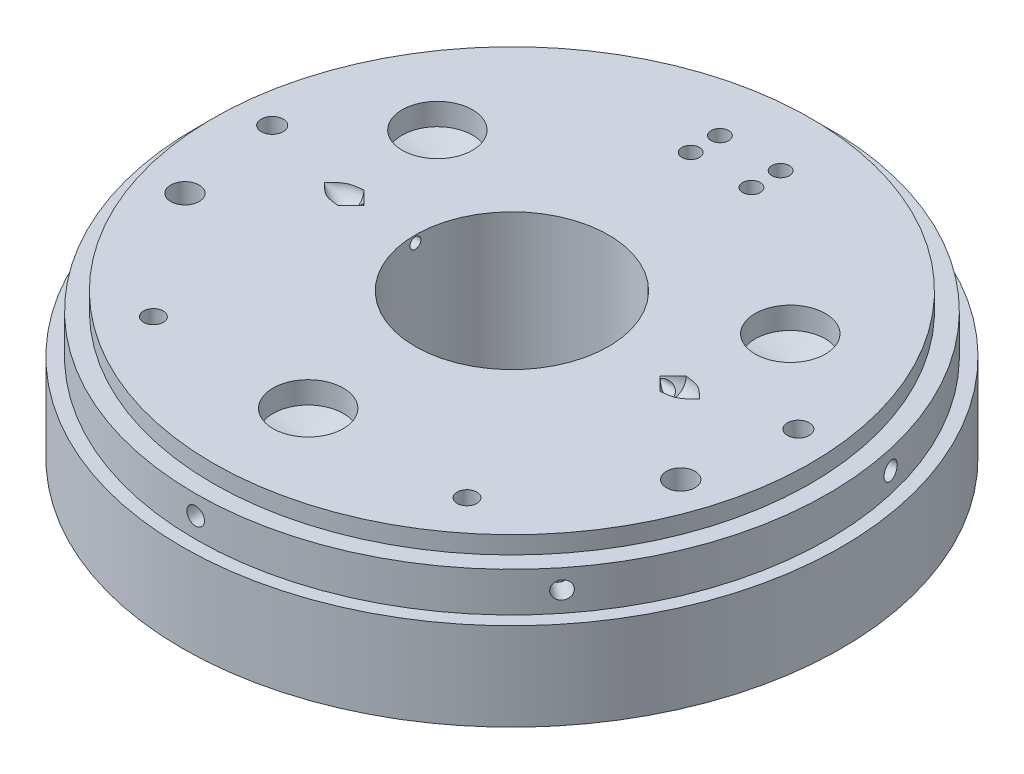
from build123d import *

# Parameters (mm, degrees)
SKETCH1_R                   = 150
EXTRUDE1_DEPTH              = 40
SKETCH2_R                   = 144
EXTRUDE2_DEPTH              = 18
SKETCH3_R                   = 136
EXTRUDE4_DEPTH              = 8
SKETCH7_R                   = 44
EXTRUDE11_DEPTH             = 100
SKETCH11_R                  = 16
EXTRUDE12_DEPTH             = 10
CIRPATTERN4_COUNT           = 3
SKETCH16_R                  = 2.5
EXTRUDE13_DEPTH             = 30
CIRPATTERN6_COUNT           = 2
SKETCH18_R                  = 5
EXTRUDE19_DEPTH             = 18
SKETCH22_R                  = 6.5
EXTRUDE20_DEPTH             = 18
SKETCH23_R                  = 4.5
EXTRUDE21_DEPTH             = 18
SKETCH24_R                  = 4
EXTRUDE23_DEPTH             = 8
SKETCH25_R                  = 16
EXTRUDE25_DEPTH             = 4
EXTRUDE25_DRAFT             = -75
CIRPATTERN7_COPY_1_SKETCH_R = 16
CIRPATTERN7_COPY_1_DEPTH    = 4
CIRPATTERN7_COPY_1_DRAFT    = -75
CIRPATTERN7_COPY_2_SKETCH_R = 16
CIRPATTERN7_COPY_2_DEPTH    = 4
CIRPATTERN7_COPY_2_DRAFT    = -75
SKETCH5_R                   = 4
EXTRUDE33_DEPTH             = 10
SKETCH33_R                  = 2
EXTRUDE34_DEPTH             = 5
CIRPATTERN10_COUNT          = 7


with BuildPart() as part:
    # Sketch1 → Extrude1 (new body)
    with BuildSketch(Plane(origin=(0, 0, 0), x_dir=(1, 0, 0), z_dir=(0, 1, 0))):
        with Locations(Location((0, 0, 0), (0, 0, 270))):
            Circle(SKETCH1_R)
    extrude(amount=EXTRUDE1_DEPTH)

    # Sketch2 → Extrude2 (add)
    with BuildSketch(Plane(origin=(0, 40, 0), x_dir=(1, 0, 0), z_dir=(0, 1, 0))):
        with Locations(Location((0, 0, 0), (0, 0, 270))):
            Circle(SKETCH2_R)
    extrude(amount=EXTRUDE2_DEPTH)

    # Sketch3 → Extrude4 (add)
    with BuildSketch(Plane(origin=(0, 58, 0), x_dir=(1, 0, 0), z_dir=(0, 1, 0))):
        with Locations(Location((0, 0, 0), (0, 0, 270))):
            Circle(SKETCH3_R)
    extrude(amount=EXTRUDE4_DEPTH)

    # Sketch7 → Extrude11 (cut)
    with BuildSketch(Plane(origin=(0, 66, 0), x_dir=(-1, 0, 0), z_dir=(0, 1, 0))):
        with Locations(Location((0, 0, 0), (0, 0, 90))):
            Circle(SKETCH7_R)
    extrude(amount=-EXTRUDE11_DEPTH, mode=Mode.SUBTRACT)

    # Sketch11 → Extrude12 (cut)
    with BuildSketch(Plane(origin=(0, 66, 0), x_dir=(1, 0, 0), z_dir=(0, 1, 0))):
        with Locations(Location((0, -92.741441023, 0), (0, 0, 270))):
            Circle(SKETCH11_R)
    extrude12 = extrude(amount=-EXTRUDE12_DEPTH, mode=Mode.SUBTRACT)

    # CirPattern4: Extrude12 ×3 about axis
    cirpattern4_axis = Axis((0, 0, 0), (0, 1, 0))
    for i in range(1, CIRPATTERN4_COUNT):
        add(extrude12.rotate(cirpattern4_axis, i * 360 / CIRPATTERN4_COUNT), mode=Mode.SUBTRACT)

    # Sketch14 → Cut-Revolve1 (revolve, cut)
    with BuildSketch(Plane(origin=(0, 66, 0), x_dir=(1, 0, 0), z_dir=(0, 1, 0))):
        with BuildLine():
            Line((-73.357030194, 0), (-67.278961327, 0))
            Line((-67.278961327, 0), (-73.357030194, 6))
            add(Edge.make_bspline(
                [(-85.357030194, 0), (-83.501718756, 1.9200594), (-80.173424478, 5.36450683), (-75.448230423, 5.805037179), (-73.357030194, 6)],
                knots=[0, 0, 0, 0, 0.557436117, 1, 1, 1, 1], degree=3))
            Line((-85.357030194, 0), (-73.357030194, 0))
        make_face()
    cut_revolve1 = revolve(axis=Axis((0, 66, 0), (-1, 0, 0)), mode=Mode.SUBTRACT)

    # Sketch16 → Extrude13 (cut)
    with BuildSketch(Plane(origin=(-43, 0, 0), x_dir=(0, 0, -1), z_dir=(1, 0, 0))):
        with Locations((0, 62.819634253)):
            Circle(SKETCH16_R)
    extrude13 = extrude(amount=-EXTRUDE13_DEPTH, mode=Mode.SUBTRACT)

    # CirPattern6: Cut-Revolve1, Extrude13 ×2 about axis
    cirpattern6_axis = Axis((0, 40, 0), (0, -1, 0))
    add([cut_revolve1.rotate(cirpattern6_axis, i * 360 / CIRPATTERN6_COUNT) for i in range(1, CIRPATTERN6_COUNT)], mode=Mode.SUBTRACT)
    add([extrude13.rotate(cirpattern6_axis, i * 360 / CIRPATTERN6_COUNT) for i in range(1, CIRPATTERN6_COUNT)], mode=Mode.SUBTRACT)

    # Sketch18 → Extrude19 (cut)
    with BuildSketch(Plane(origin=(0, 66, 0), x_dir=(-1, 0, 0), z_dir=(0, 1, 0))):
        with Locations(Location((-119.722485041, -10.622792815, 0), (0, 0, 90))):
            Circle(SKETCH18_R)
    extrude19 = extrude(amount=-EXTRUDE19_DEPTH, mode=Mode.SUBTRACT)

    # Sketch22 → Extrude20 (cut)
    with BuildSketch(Plane(origin=(0, 66, 0), x_dir=(-1, 0, 0), z_dir=(0, 1, 0))):
        with Locations(Location((-112.815418597, 35.999905687, 0), (0, 0, 90))):
            Circle(SKETCH22_R)
    extrude20 = extrude(amount=-EXTRUDE20_DEPTH, mode=Mode.SUBTRACT)

    # Sketch23 → Extrude21 (cut)
    with BuildSketch(Plane(origin=(0, 66, 0), x_dir=(-1, 0, 0), z_dir=(0, 1, 0))):
        with Locations(Location((-71.373019928, 91.832026115, 0), (0, 0, 90))):
            Circle(SKETCH23_R)
    extrude21 = extrude(amount=-EXTRUDE21_DEPTH, mode=Mode.SUBTRACT)

    # Sketch24 → Extrude23 (cut)
    with BuildSketch(Plane(origin=(0, 66, 0), x_dir=(-1, 0, 0), z_dir=(0, 1, 0))):
        with Locations(Location((-13.814132889, -108.472900781, 0), (0, 0, 90))):
            Circle(SKETCH24_R)
        with Locations(Location((-13.814132889, -95.185137879, 0), (0, 0, 90))):
            Circle(SKETCH24_R)
    extrude23 = extrude(amount=-EXTRUDE23_DEPTH, mode=Mode.SUBTRACT)

    # Mirror3: Extrude19, Extrude20, Extrude21, Extrude23 across plane
    add(extrude19.mirror(Plane(origin=(0, 0, 0), x_dir=(0, 0, 1), z_dir=(1, 0, 0))), mode=Mode.SUBTRACT)
    add(extrude20.mirror(Plane(origin=(0, 0, 0), x_dir=(0, 0, 1), z_dir=(1, 0, 0))), mode=Mode.SUBTRACT)
    add(extrude21.mirror(Plane(origin=(0, 0, 0), x_dir=(0, 0, 1), z_dir=(1, 0, 0))), mode=Mode.SUBTRACT)
    add(extrude23.mirror(Plane(origin=(0, 0, 0), x_dir=(0, 0, 1), z_dir=(1, 0, 0))), mode=Mode.SUBTRACT)


with BuildPart() as extrude25_tool:
    # Sketch25 → Extrude25 (with draft: the straight prism first)
    with BuildSketch(Plane(origin=(0, 56, 0), x_dir=(1, 0, 0), z_dir=(0, 1, 0))):
        with Locations(Location((-80.316443909, 46.370720511, 0), (0, 0, 270))):
            Circle(SKETCH25_R)
    extrude(amount=-EXTRUDE25_DEPTH)
    # Extrude25: the draft: its side faces are tilted about the plane it starts from
    extrude25_sides = [extrude25_tool.faces().sort_by_distance(p)[0] for p in [
        (-80.316443909, 54, -62.370720511),
    ]]
    draft(extrude25_sides, Plane(origin=(0, 56, 0), x_dir=(1, 0, 0), z_dir=(0, 1, 0)), EXTRUDE25_DRAFT)


with BuildPart() as part_1:
    add(part.part)

    # Extrude25: cut by extrude25_tool
    add(extrude25_tool.part, mode=Mode.SUBTRACT)


with BuildPart() as cirpattern7_copy_1_tool:
    # CirPattern7 copy 1 sketch → CirPattern7 copy 1 (with draft: the straight prism first)
    with BuildSketch(Plane(origin=(0, 56, 0), x_dir=(-0.4999999999999998, 0, -0.8660254037844387), z_dir=(0, 1, 0))):
        with Locations(Location((-80.316443909, 46.370720511, 0), (0, 0, 270))):
            Circle(CIRPATTERN7_COPY_1_SKETCH_R)
    extrude(amount=-CIRPATTERN7_COPY_1_DEPTH)
    # CirPattern7 copy 1: the draft: its side faces are tilted about the plane it starts from
    cirpattern7_copy_1_sides = [cirpattern7_copy_1_tool.faces().sort_by_distance(p)[0] for p in [
        (-13.85640646, 54, 100.741441022),
    ]]
    draft(cirpattern7_copy_1_sides, Plane(origin=(0, 56, 0), x_dir=(-0.4999999999999998, 0, -0.8660254037844387), z_dir=(0, 1, 0)), CIRPATTERN7_COPY_1_DRAFT)


with BuildPart() as part_2:
    add(part_1.part)

    # CirPattern7 copy 1: cut by cirpattern7_copy_1_tool
    add(cirpattern7_copy_1_tool.part, mode=Mode.SUBTRACT)


with BuildPart() as cirpattern7_copy_2_tool:
    # CirPattern7 copy 2 sketch → CirPattern7 copy 2 (with draft: the straight prism first)
    with BuildSketch(Plane(origin=(0, 56, 0), x_dir=(-0.5000000000000004, 0, 0.8660254037844384), z_dir=(0, 1, 0))):
        with Locations(Location((-80.316443909, 46.370720511, 0), (0, 0, 270))):
            Circle(CIRPATTERN7_COPY_2_SKETCH_R)
    extrude(amount=-CIRPATTERN7_COPY_2_DEPTH)
    # CirPattern7 copy 2: the draft: its side faces are tilted about the plane it starts from
    cirpattern7_copy_2_sides = [cirpattern7_copy_2_tool.faces().sort_by_distance(p)[0] for p in [
        (94.172850369, 54, -38.370720511),
    ]]
    draft(cirpattern7_copy_2_sides, Plane(origin=(0, 56, 0), x_dir=(-0.5000000000000004, 0, 0.8660254037844384), z_dir=(0, 1, 0)), CIRPATTERN7_COPY_2_DRAFT)


with BuildPart() as part_3:
    add(part_2.part)

    # CirPattern7 copy 2: cut by cirpattern7_copy_2_tool
    add(cirpattern7_copy_2_tool.part, mode=Mode.SUBTRACT)

    # Extrude27 cone 1 section (through the dimple's axis) → Extrude27 (revolve, cut)
    with BuildSketch(Plane(origin=(-119.722485041, 48, -10.622792815), x_dir=(0, 0, 1), z_dir=(1, 0, 0))):
        Polygon((0, 0), (5, 0), (0, 1.819851171), align=None)
    extrude27 = revolve(axis=Axis((-119.722485041, 48, -10.622792815), (0, -1, 0)), mode=Mode.SUBTRACT)

    # Extrude29 cone 1 section (through the dimple's axis) → Extrude29 (revolve, cut)
    with BuildSketch(Plane(origin=(-112.815418597, 48, 35.999905687), x_dir=(0, 0, 1), z_dir=(1, 0, 0))):
        Polygon((0, 0), (6.5, 0), (0, 1.741669751), align=None)
    extrude29 = revolve(axis=Axis((-112.815418597, 48, 35.999905687), (0, -1, 0)), mode=Mode.SUBTRACT)

    # Extrude30 cone 1 section (through the dimple's axis) → Extrude30 (revolve, cut)
    with BuildSketch(Plane(origin=(-71.373019928, 48, 91.832026115), x_dir=(0, 0, 1), z_dir=(1, 0, 0))):
        Polygon((0, 0), (4.5, 0), (0, 1.205771366), align=None)
    extrude30 = revolve(axis=Axis((-71.373019928, 48, 91.832026115), (0, -1, 0)), mode=Mode.SUBTRACT)

    # Extrude31 cone 1 section (through the dimple's axis) → Extrude31 (revolve, cut)
    with BuildSketch(Plane(origin=(-13.814132889, 58, -108.472900781), x_dir=(0, 0, 1), z_dir=(1, 0, 0))):
        Polygon((0, 0), (4, 0), (0, 1.07179677), align=None)
    extrude31 = revolve(axis=Axis((-13.814132889, 58, -108.472900781), (0, -1, 0)), mode=Mode.SUBTRACT)

    # Extrude32 cone 1 section (through the dimple's axis) → Extrude32 (revolve, cut)
    with BuildSketch(Plane(origin=(-13.814132889, 58, -95.185137879), x_dir=(0, 0, 1), z_dir=(1, 0, 0))):
        Polygon((0, 0), (4, 0), (0, 1.07179677), align=None)
    extrude32 = revolve(axis=Axis((-13.814132889, 58, -95.185137879), (0, -1, 0)), mode=Mode.SUBTRACT)

    # Mirror4: Extrude27, Extrude29, Extrude30, Extrude31, Extrude32 across plane
    add(extrude27.mirror(Plane(origin=(0, 0, 0), x_dir=(0, 0, 1), z_dir=(1, 0, 0))), mode=Mode.SUBTRACT)
    add(extrude29.mirror(Plane(origin=(0, 0, 0), x_dir=(0, 0, 1), z_dir=(1, 0, 0))), mode=Mode.SUBTRACT)
    add(extrude30.mirror(Plane(origin=(0, 0, 0), x_dir=(0, 0, 1), z_dir=(1, 0, 0))), mode=Mode.SUBTRACT)
    add(extrude31.mirror(Plane(origin=(0, 0, 0), x_dir=(0, 0, 1), z_dir=(1, 0, 0))), mode=Mode.SUBTRACT)
    add(extrude32.mirror(Plane(origin=(0, 0, 0), x_dir=(0, 0, 1), z_dir=(1, 0, 0))), mode=Mode.SUBTRACT)

    # Sketch5 → Extrude33 (cut)
    with BuildSketch(Plane.XY.offset(144)):
        with Locations((0, 49.243661566)):
            Circle(SKETCH5_R)
    extrude33 = extrude(amount=-EXTRUDE33_DEPTH, mode=Mode.SUBTRACT)

    # Sketch33 → Extrude34 (cut)
    with BuildSketch(Plane.XY.offset(134)):
        with Locations((0, 49.243661566)):
            Circle(SKETCH33_R)
    extrude34 = extrude(amount=-EXTRUDE34_DEPTH, mode=Mode.SUBTRACT)

    # Extrude36 cone 1 section (through the dimple's axis) → Extrude36 (revolve, cut)
    with BuildSketch(Plane(origin=(0, 49.243661566, 129), x_dir=(0, -1, 0), z_dir=(1, 0, 0))):
        Polygon((0, 0), (2, 0), (0, 0.535898385), align=None)
    extrude36 = revolve(axis=Axis((0, 49.243661566, 129), (0, 0, -1)), mode=Mode.SUBTRACT)

    # CirPattern10: Extrude33, Extrude34, Extrude36 ×7 about axis
    cirpattern10_axis = Axis((0, 0, 0), (0, 1, 0))
    add([extrude33.rotate(cirpattern10_axis, i * 360 / CIRPATTERN10_COUNT) for i in range(1, CIRPATTERN10_COUNT)], mode=Mode.SUBTRACT)
    add([extrude34.rotate(cirpattern10_axis, i * 360 / CIRPATTERN10_COUNT) for i in range(1, CIRPATTERN10_COUNT)], mode=Mode.SUBTRACT)
    add([extrude36.rotate(cirpattern10_axis, i * 360 / CIRPATTERN10_COUNT) for i in range(1, CIRPATTERN10_COUNT)], mode=Mode.SUBTRACT)


solid = part_3.part
